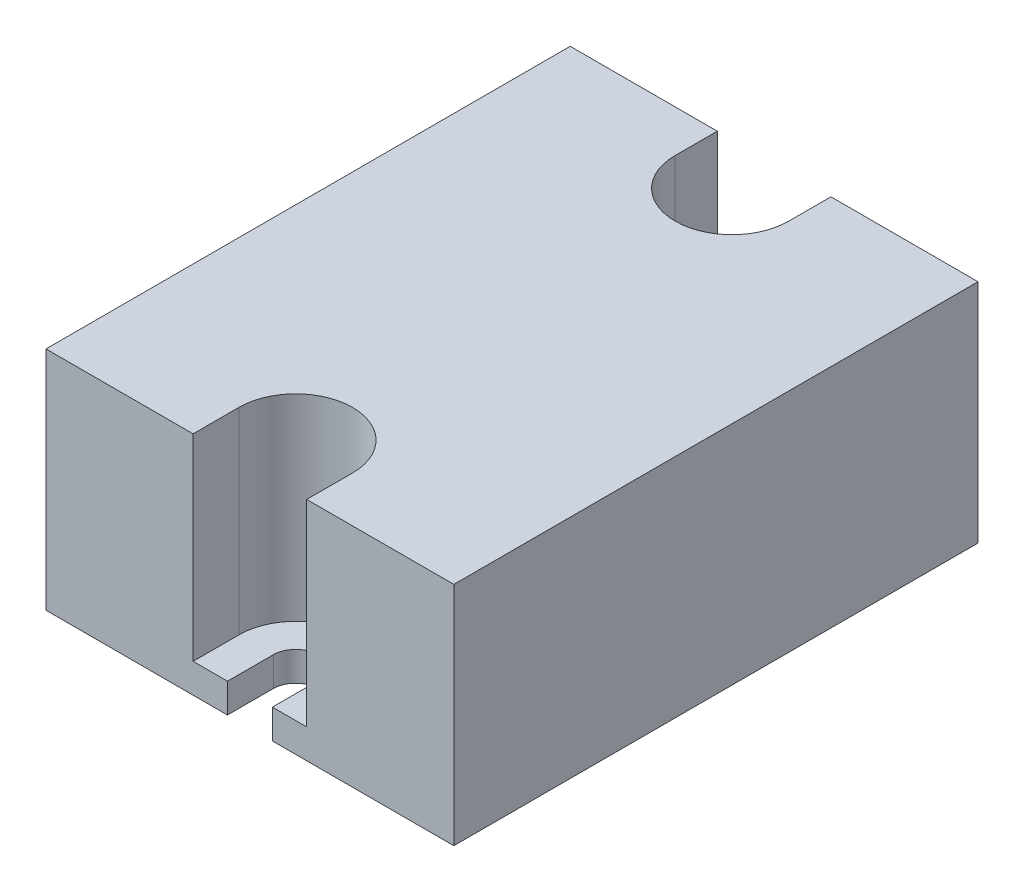
from build123d import *

# Parameters (mm, degrees)
SKETCH1_R           = 2.45
BOSS_EXTRUDE1_DEPTH = 3.2
BOSS_EXTRUDE2_DEPTH = 21.5


with BuildPart() as part:
    # Sketch1 → Boss-Extrude1 (new body)
    with BuildSketch(Plane(origin=(0, 0, 0), x_dir=(1, 0, 0), z_dir=(0, 1, 0))):
        with BuildLine():
            Line((0, 0), (19.8, 0))
            Line((19.8, 0), (19.8, 5))
            ThreePointArc((19.8, 5), (22.25, 7.45), (24.7, 5))
            Line((24.7, 5), (24.7, 0))
            Line((24.7, 0), (44.5, 0))
            Line((44.5, 0), (44.5, 57.2))
            Line((44.5, 57.2), (28.45, 57.2))
            Line((28.45, 57.2), (16.05, 57.2))
            Line((16.05, 57.2), (0, 57.2))
            Line((0, 57.2), (0, 0))
        make_face()
        with Locations((22.25, 52.6)):
            Circle(SKETCH1_R, mode=Mode.SUBTRACT)
    extrude(amount=BOSS_EXTRUDE1_DEPTH)

    # Sketch2 → Boss-Extrude2 (add)
    with BuildSketch(Plane(origin=(0, 3.2, 0), x_dir=(1, 0, 0), z_dir=(0, 1, 0))):
        with BuildLine():
            Line((0, 0), (0, 57.2))
            Line((0, 57.2), (16.05, 57.2))
            Line((16.05, 57.2), (16.05, 52.6))
            ThreePointArc((16.05, 52.6), (22.25, 46.4), (28.45, 52.6))
            Line((28.45, 52.6), (28.45, 57.2))
            Line((28.45, 57.2), (44.5, 57.2))
            Line((44.5, 57.2), (44.5, 0))
            Line((44.5, 0), (28.45, 0))
            Line((28.45, 0), (28.45, 5))
            ThreePointArc((28.45, 5), (22.25, 11.2), (16.05, 5))
            Line((16.05, 5), (16.05, 0))
            Line((16.05, 0), (0, 0))
        make_face()
    extrude(amount=BOSS_EXTRUDE2_DEPTH)


solid = part.part
